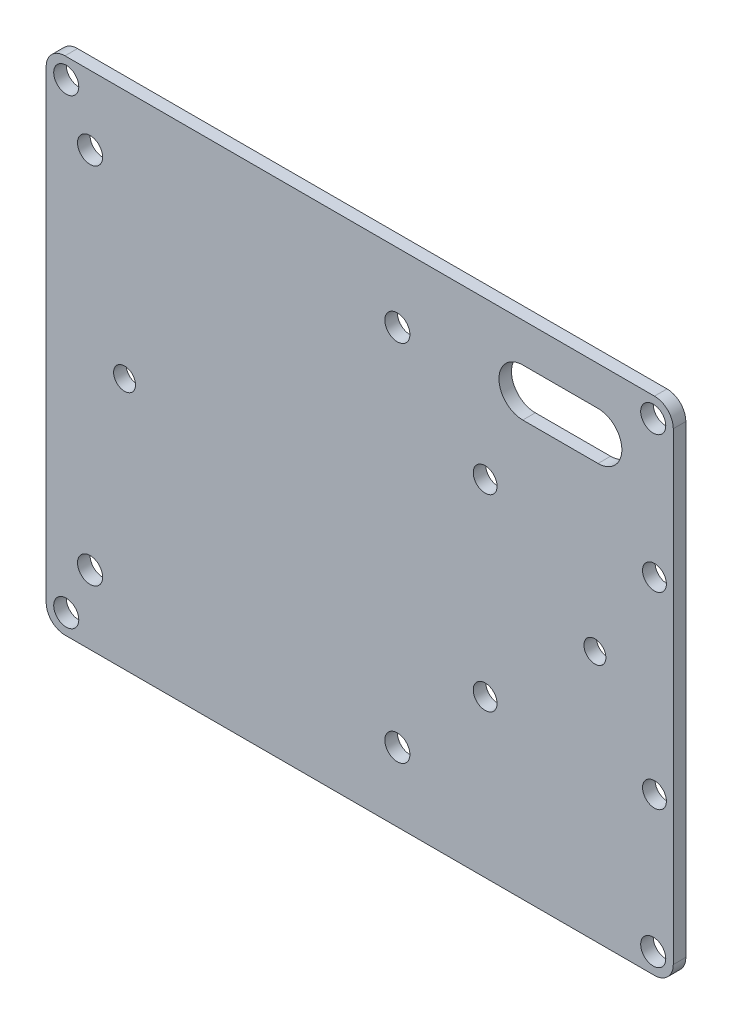
from build123d import *

# Parameters (mm, degrees)
EXTRUDE_1_DEPTH     = 2
SKETCH_2_R          = 2
SKETCH_2_R_2        = 1.9
CUT_EXTRUDE_1_DEPTH = 3
CUT_EXTRUDE_2_DEPTH = 3
SKETCH_4_R          = 1.75
CUT_EXTRUDE_3_DEPTH = 3


with BuildPart() as part:
    # 草图1 → 凸台-拉伸1 (new body)
    with BuildSketch(Plane.XY):
        with BuildLine():
            Line((-47, 40), (47, 40))
            ThreePointArc((47, 40), (49.121320344, 39.121320344), (50, 37))
            Line((50, 37), (50, -37))
            ThreePointArc((50, -37), (49.121320344, -39.121320344), (47, -40))
            Line((47, -40), (-47, -40))
            ThreePointArc((-47, -40), (-49.121320344, -39.121320344), (-50, -37))
            Line((-50, -37), (-50, 37))
            ThreePointArc((-50, 37), (-49.121320344, 39.121320344), (-47, 40))
        make_face()
    extrude(amount=EXTRUDE_1_DEPTH)

    # 草图2 → 切除-拉伸1 (cut, through all)
    with BuildSketch(Plane.XY.offset(2)):
        with Locations((-46.8, 36.8)):
            Circle(SKETCH_2_R)
        with Locations((46.8, 36.8)):
            Circle(SKETCH_2_R)
        with Locations((46.8, -36.8)):
            Circle(SKETCH_2_R)
        with Locations((-46.8, -36.8)):
            Circle(SKETCH_2_R)
        with Locations((-43, 29)):
            Circle(SKETCH_2_R)
        with Locations((6, 29)):
            Circle(SKETCH_2_R)
        with Locations((6, -29)):
            Circle(SKETCH_2_R)
        with Locations((-43, -29)):
            Circle(SKETCH_2_R)
        with Locations((47, -15)):
            Circle(SKETCH_2_R_2)
        with Locations((20, 15)):
            Circle(SKETCH_2_R_2)
        with Locations((20, -15)):
            Circle(SKETCH_2_R_2)
        with Locations((47, 15)):
            Circle(SKETCH_2_R_2)
    extrude(amount=-CUT_EXTRUDE_1_DEPTH, mode=Mode.SUBTRACT)

    # 草图3 → 切除-拉伸2 (cut, through all)
    with BuildSketch(Plane.XY.offset(2)):
        with BuildLine():
            Line((26, 33.8), (38, 33.8))
            ThreePointArc((38, 33.8), (41.8, 30), (38, 26.2))
            Line((38, 26.2), (26, 26.2))
            ThreePointArc((26, 26.2), (22.2, 30), (26, 33.8))
        make_face()
    extrude(amount=-CUT_EXTRUDE_2_DEPTH, mode=Mode.SUBTRACT)

    # 草图4 → 切除-拉伸3 (cut, through all)
    with BuildSketch(Plane.XY.offset(2)):
        with Locations((-37.5, 0.169558906)):
            Circle(SKETCH_4_R)
        with Locations((37.5, 0)):
            Circle(SKETCH_4_R)
    extrude(amount=-CUT_EXTRUDE_3_DEPTH, mode=Mode.SUBTRACT)


solid = part.part
